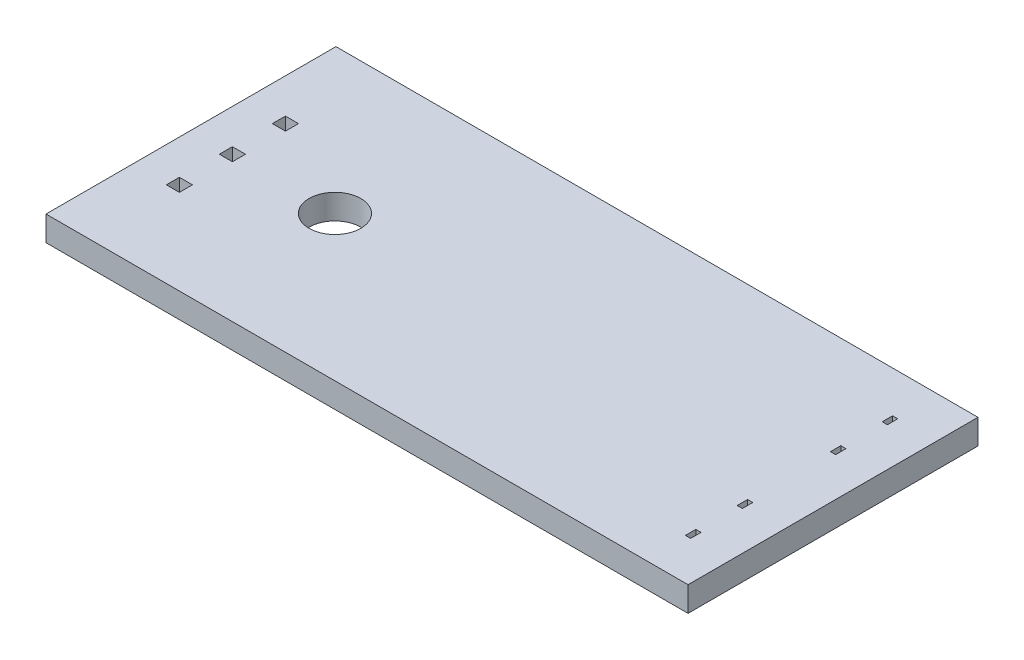
from build123d import *

# Parameters (mm, degrees)
SKETCH1_W           = 31
SKETCH1_H           = 14
BOSS_EXTRUDE1_DEPTH = 1.2
SKETCH2_R           = 1.25
SKETCH2_W           = 0.63
SKETCH2_H           = 0.63
SKETCH2_W_2         = 0.25
SKETCH2_H_2         = 0.5
CUT_EXTRUDE1_DEPTH  = 2.2


with BuildPart() as part:
    # Sketch1 → Boss-Extrude1 (new body)
    with BuildSketch(Plane(origin=(0, 0, 0), x_dir=(1, 0, 0), z_dir=(0, 1, 0))):
        with Locations((-0.25, 0.35546875)):
            Rectangle(SKETCH1_W, SKETCH1_H)
    extrude(amount=BOSS_EXTRUDE1_DEPTH)

    # Sketch2 → Cut-Extrude1 (cut, through all)
    with BuildSketch(Plane(origin=(0, 1.2, 0), x_dir=(1, 0, 0), z_dir=(0, 1, 0))):
        with Locations((-8.8, 0.35546875)):
            Circle(SKETCH2_R)
        with Locations((-13.75, 2.91546875)):
            Rectangle(SKETCH2_W, SKETCH2_H)
        with Locations((-13.75, 0.35546875)):
            Rectangle(SKETCH2_W, SKETCH2_H)
        with Locations((-13.75, -2.20453125)):
            Rectangle(SKETCH2_W, SKETCH2_H)
        with Locations((13.25, -4.39453125)):
            Rectangle(SKETCH2_W_2, SKETCH2_H_2)
        with Locations((13.25, -1.89453125)):
            Rectangle(SKETCH2_W_2, SKETCH2_H_2)
        with Locations((13.25, 2.60546875)):
            Rectangle(SKETCH2_W_2, SKETCH2_H_2)
        with Locations((13.25, 5.10546875)):
            Rectangle(SKETCH2_W_2, SKETCH2_H_2)
    extrude(amount=-CUT_EXTRUDE1_DEPTH, mode=Mode.SUBTRACT)


solid = part.part
